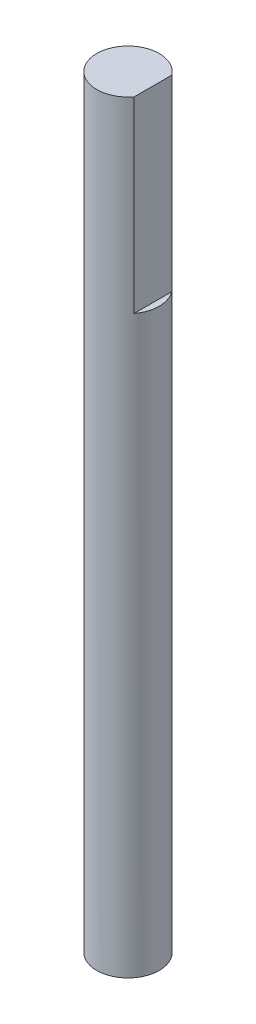
from build123d import *

# Parameters (mm, degrees)
SALIENTE_EXTRUIR1_DEPTH = 15
CROQUIS2_R              = 2.5
SALIENTE_EXTRUIR2_DEPTH = 46


with BuildPart() as part:
    # Croquis1 → Saliente-Extruir1 (new body)
    with BuildSketch(Plane(origin=(0, 0, 0), x_dir=(1, 0, 0), z_dir=(0, 1, 0))):
        with BuildLine():
            Line((2, 1.5), (2, -1.5))
            ThreePointArc((2, -1.5), (-2.5, 0), (2, 1.5))
        make_face()
    extrude(amount=SALIENTE_EXTRUIR1_DEPTH)

    # Croquis2 → Saliente-Extruir2 (add)
    with BuildSketch(Plane(origin=(0, 0, 0), x_dir=(1, 0, 0), z_dir=(0, 1, 0))):
        Circle(CROQUIS2_R)
    extrude(amount=-SALIENTE_EXTRUIR2_DEPTH)


solid = part.part
